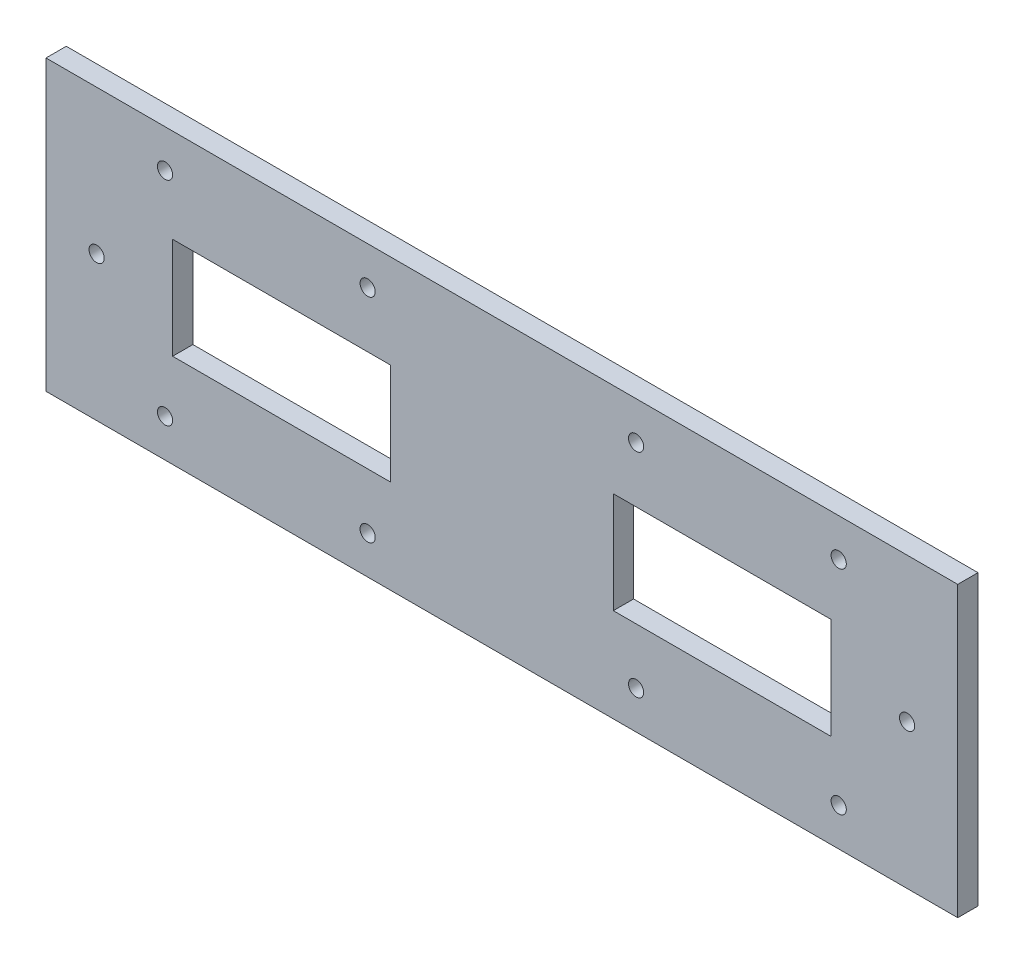
from build123d import *

# Parameters (mm, degrees)
SKETCH1_R           = 1.5
SKETCH1_W           = 43
SKETCH1_H           = 20
BOSS_EXTRUDE3_DEPTH = 4


with BuildPart() as part:
    # Sketch1 → Boss-Extrude3 (new body)
    with BuildSketch(Plane.XY):
        Polygon((8.44359092, 25.723284589), (-71.55640908, 25.723284589), (-71.55640908, -31.276715411), (8.44359092, -31.276715411), (28.44359092, -31.276715411), (108.44359092, -31.276715411), (108.44359092, 25.723284589), (28.44359092, 25.723284589), align=None)
        with Locations((-48.05640908, -23.776715411)):
            Circle(SKETCH1_R, mode=Mode.SUBTRACT)
        with Locations((-8.05640908, -23.776715411)):
            Circle(SKETCH1_R, mode=Mode.SUBTRACT)
        with Locations((-61.55640908, -2.776715411)):
            Circle(SKETCH1_R, mode=Mode.SUBTRACT)
        with Locations((-25.05640908, -2.776715411)):
            Rectangle(SKETCH1_W, SKETCH1_H, mode=Mode.SUBTRACT)
        with Locations((44.94359092, -23.776715411)):
            Circle(SKETCH1_R, mode=Mode.SUBTRACT)
        with Locations((84.94359092, -23.776715411)):
            Circle(SKETCH1_R, mode=Mode.SUBTRACT)
        with Locations((61.94359092, -2.776715411)):
            Rectangle(SKETCH1_W, SKETCH1_H, mode=Mode.SUBTRACT)
        with Locations((98.44359092, -2.776715411)):
            Circle(SKETCH1_R, mode=Mode.SUBTRACT)
        with Locations((-48.05640908, 18.223284589)):
            Circle(SKETCH1_R, mode=Mode.SUBTRACT)
        with Locations((-8.05640908, 18.223284589)):
            Circle(SKETCH1_R, mode=Mode.SUBTRACT)
        with Locations((44.94359092, 18.223284589)):
            Circle(SKETCH1_R, mode=Mode.SUBTRACT)
        with Locations((84.94359092, 18.223284589)):
            Circle(SKETCH1_R, mode=Mode.SUBTRACT)
    extrude(amount=-BOSS_EXTRUDE3_DEPTH)


solid = part.part
